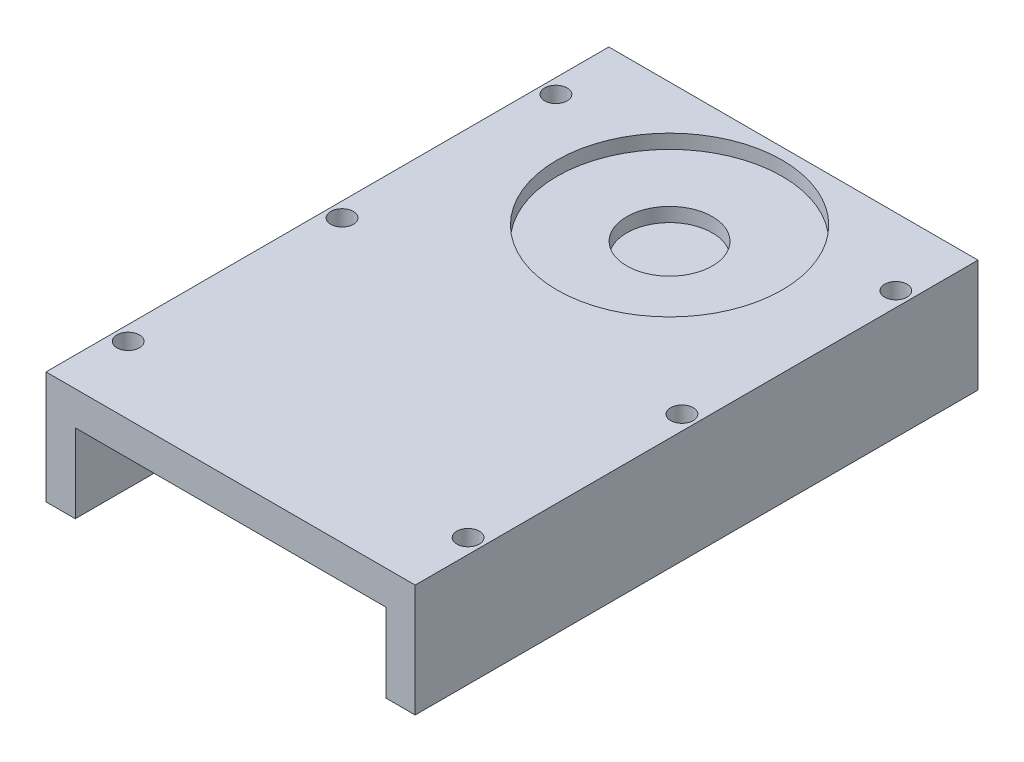
from build123d import *

# Parameters (mm, degrees)
BOSS_EXTRUDE1_DEPTH = 63.5
SKETCH4_R           = 1.27
CUT_EXTRUDE2_DEPTH  = 63.5
SKETCH6_R           = 12.7
CUT_EXTRUDE7_DEPTH  = 1.5875
SKETCH8_R           = 4.826
CUT_EXTRUDE8_DEPTH  = 1.5875


with BuildPart() as part:
    # Sketch2 → Boss-Extrude1 (new body)
    with BuildSketch(Plane.XY):
        Polygon((-18.314458333, 3.81), (20.828, 3.81), (20.828, -8.89), (17.526, -8.89), (17.526, 0), (-17.526, 0), (-17.526, -8.89), (-20.828, -8.89), (-20.828, 3.81), align=None)
    extrude(amount=BOSS_EXTRUDE1_DEPTH)

    # Sketch4 → Cut-Extrude2 (cut)
    with BuildSketch(Plane.XZ.offset(8.89)):
        with Locations((-19.177, 7.62)):
            Circle(SKETCH4_R)
        with Locations((-19.177, 55.88)):
            Circle(SKETCH4_R)
        with Locations((-19.177, 31.75)):
            Circle(SKETCH4_R)
    cut_extrude2 = extrude(amount=-CUT_EXTRUDE2_DEPTH, mode=Mode.SUBTRACT)

    # Mirror1: Cut-Extrude2 across plane
    add(cut_extrude2.mirror(Plane(origin=(0, 0, 0), x_dir=(0, 0, 1), z_dir=(1, 0, 0))), mode=Mode.SUBTRACT)

    # Sketch6 → Cut-Extrude7 (cut)
    with BuildSketch(Plane(origin=(0, 3.81, 0), x_dir=(1, 0, 0), z_dir=(0, 1, 0))):
        with Locations((0, -13.97)):
            Circle(SKETCH6_R)
    extrude(amount=-CUT_EXTRUDE7_DEPTH, mode=Mode.SUBTRACT)

    # Sketch8 → Cut-Extrude8 (cut)
    with BuildSketch(Plane(origin=(0, 2.2225, 0), x_dir=(1, 0, 0), z_dir=(0, 1, 0))):
        with Locations((0, -13.97)):
            Circle(SKETCH8_R)
    extrude(amount=-CUT_EXTRUDE8_DEPTH, mode=Mode.SUBTRACT)


solid = part.part
